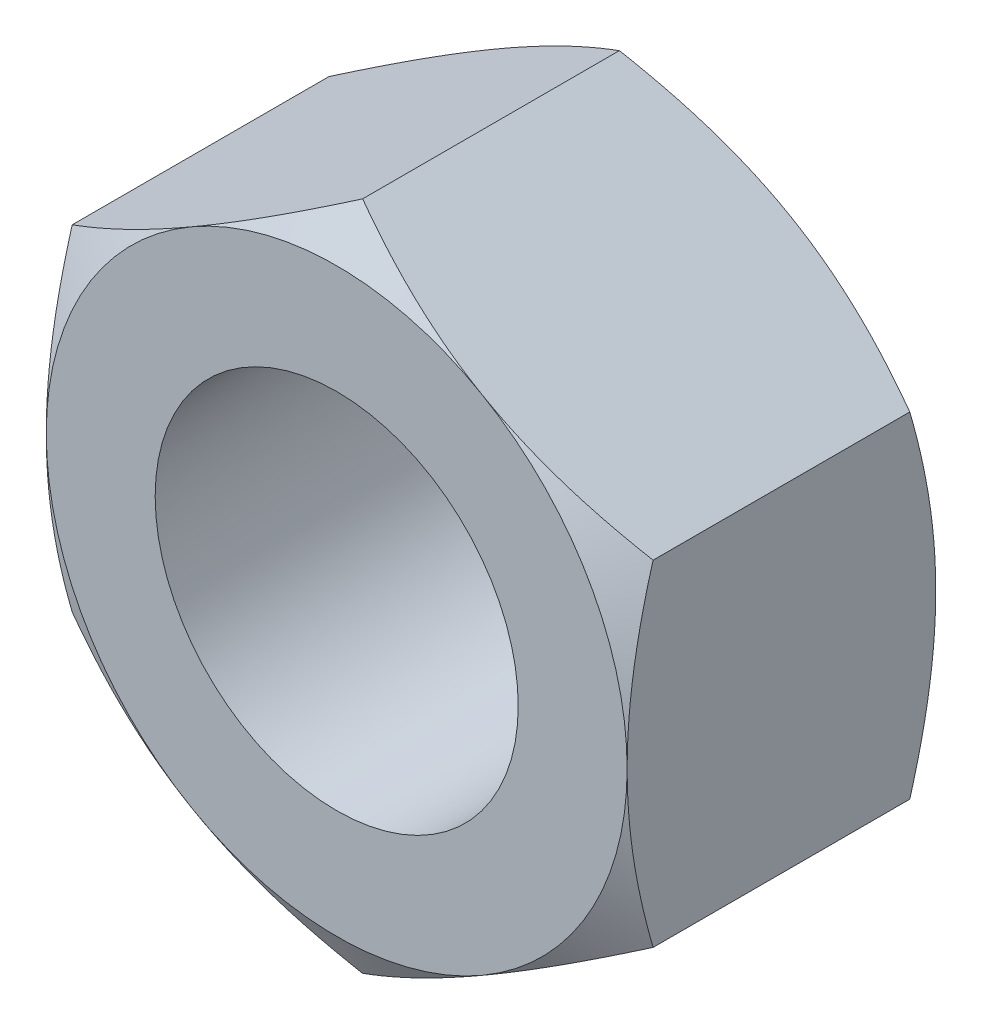
from build123d import *

# Parameters (mm, degrees)
SKETCH1_R               = 3.96875
EXTRUDE1_DEPTH          = 3.3734375
SKETCH7_OUTSIDE_W       = 106.796
SKETCH7_OUTSIDE_H       = 108.76
SKETCH7_OUTSIDE_R       = 6.35
EXTRUDE2_DEPTH          = 25.4
EXTRUDE2_DRAFT          = -60
MIRROR1_COPY_1_SKETCH_W = 106.796
MIRROR1_COPY_1_SKETCH_H = 108.76
MIRROR1_COPY_1_SKETCH_R = 6.35
MIRROR1_COPY_1_DEPTH    = 25.4
MIRROR1_COPY_1_DRAFT    = -60


with BuildPart() as part:
    # Sketch1 → Extrude1 (new, symmetric)
    with BuildSketch(Plane.XY):
        Polygon((-6.35, 3.666174209), (-6.35, -3.666174209), (0, -7.332348419), (6.35, -3.666174209), (6.35, 3.666174209), (0, 7.332348419), align=None)
        Circle(SKETCH1_R, mode=Mode.SUBTRACT)
    extrude(amount=EXTRUDE1_DEPTH, both=True)


with BuildPart() as extrude2_tool:
    # Sketch7 outside → Extrude2 (with draft: the straight prism first)
    with BuildSketch(Plane.XY.offset(3.3734375)):
        Rectangle(SKETCH7_OUTSIDE_W, SKETCH7_OUTSIDE_H)
        Circle(SKETCH7_OUTSIDE_R, mode=Mode.SUBTRACT)
    extrude(amount=-EXTRUDE2_DEPTH)
    # Extrude2: the draft: its side faces are tilted about the plane it starts from
    extrude2_sides = [extrude2_tool.faces().sort_by_distance(p)[0] for p in [
        (0, -54.38, -9.3265625),
        (53.398, 0, -9.3265625),
        (0, 54.38, -9.3265625),
        (-53.398, 0, -9.3265625),
        (-6.35, 0, -9.3265625),
    ]]
    draft(extrude2_sides, Plane.XY.offset(3.3734375), EXTRUDE2_DRAFT)


with BuildPart() as part_1:
    add(part.part)

    # Extrude2: cut by extrude2_tool
    add(extrude2_tool.part, mode=Mode.SUBTRACT)


with BuildPart() as mirror1_copy_1_tool:
    # Mirror1 copy 1 sketch → Mirror1 copy 1 (with draft: the straight prism first)
    with BuildSketch(Plane(origin=(0, 0, -3.3734375), x_dir=(1, 0, 0), z_dir=(0, 0, -1))):
        Rectangle(MIRROR1_COPY_1_SKETCH_W, MIRROR1_COPY_1_SKETCH_H)
        Circle(MIRROR1_COPY_1_SKETCH_R, mode=Mode.SUBTRACT)
    extrude(amount=-MIRROR1_COPY_1_DEPTH)
    # Mirror1 copy 1: the draft: its side faces are tilted about the plane it starts from
    mirror1_copy_1_sides = [mirror1_copy_1_tool.faces().sort_by_distance(p)[0] for p in [
        (0, -54.38, 9.3265625),
        (53.398, 0, 9.3265625),
        (0, 54.38, 9.3265625),
        (-53.398, 0, 9.3265625),
        (-6.35, 0, 9.3265625),
    ]]
    draft(mirror1_copy_1_sides, Plane(origin=(0, 0, -3.3734375), x_dir=(1, 0, 0), z_dir=(0, 0, -1)), MIRROR1_COPY_1_DRAFT)


with BuildPart() as part_2:
    add(part_1.part)

    # Mirror1 copy 1: cut by mirror1_copy_1_tool
    add(mirror1_copy_1_tool.part, mode=Mode.SUBTRACT)


solid = part_2.part
